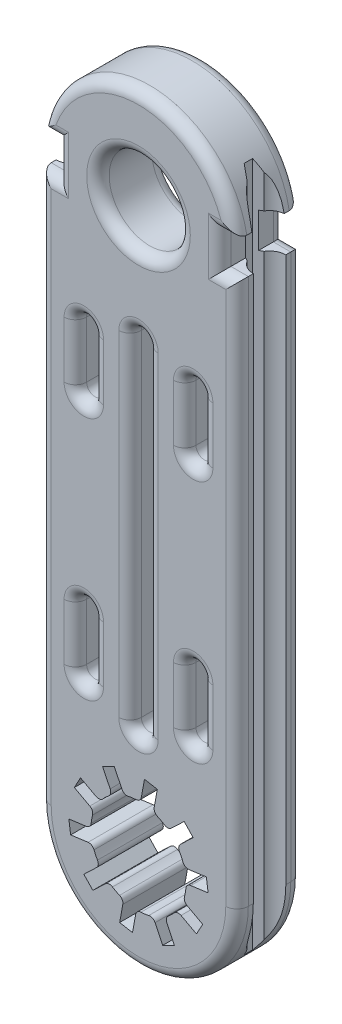
from build123d import *

# Parameters (mm, degrees)
SALIENTE_EXTRUIR1_DEPTH      = 3
SALIENTE_EXTRUIR1_DEPTH_BACK = 2.78
CROQUIS2_W                   = 17.498184
CROQUIS2_H                   = 5.77054
SALIENTE_EXTRUIR2_DEPTH      = 50
CROQUIS4_R                   = 8.749092
SALIENTE_EXTRUIR3_DEPTH      = 5.78
CROQUIS5_R                   = 3.6
CROQUIS5_R_2                 = 3.15
CORTAR_EXTRUIR1_DEPTH        = 12
CROQUIS6_W                   = 2.138247
CROQUIS6_H                   = 3.107333
CORTAR_EXTRUIR2_DEPTH        = 9
CORTAR_EXTRUIR3_DEPTH        = 10
CORTAR_EXTRUIR4_DEPTH        = 10
CROQUIS9_R                   = 63.746793
CORTAR_EXTRUIR5_DEPTH        = 3
REDONDEO1_R                  = 1
CORTAR_EXTRUIR6_DEPTH        = 73
CORTAR_EXTRUIR7_DEPTH        = 8


with BuildPart() as part:
    # Croquis1 → Saliente-Extruir1 (new body, two sides)
    with BuildSketch(Plane.XY) as saliente_extruir1_sk:
        with BuildLine():
            Line((-0.091551, 52.561209), (5.657541, 52.561209))
            ThreePointArc((5.657541, 52.561209), (8.657541, 49.561209), (11.657541, 52.561209))
            Line((11.657541, 52.561209), (17.406633, 52.561209))
            ThreePointArc((17.406633, 52.561209), (8.657541, 43.812117), (-0.091551, 52.561209))
        make_face()
    extrude(amount=SALIENTE_EXTRUIR1_DEPTH)
    extrude(saliente_extruir1_sk.sketch, amount=-SALIENTE_EXTRUIR1_DEPTH_BACK)

    # Croquis2 → Saliente-Extruir2 (add)
    with BuildSketch(Plane(origin=(0, 52.561209, 0), x_dir=(1, 0, 0), z_dir=(0, 1, 0))):
        with Locations((8.657541, -0.11473)):
            Rectangle(CROQUIS2_W, CROQUIS2_H)
    extrude(amount=SALIENTE_EXTRUIR2_DEPTH)

    # Croquis4 → Saliente-Extruir3 (add, through all)
    with BuildSketch(Plane.XY.offset(3)):
        with Locations((8.657541, 102.561209)):
            Circle(CROQUIS4_R)
    extrude(amount=-SALIENTE_EXTRUIR3_DEPTH)

    # Croquis5 → Cortar-Extruir1 (cut)
    with BuildSketch(Plane.XY.offset(3)):
        with Locations((8.657541, 102.561209)):
            Circle(CROQUIS5_R)
        with Locations((8.657541, 52.561209)):
            Circle(CROQUIS5_R_2)
    extrude(amount=-CORTAR_EXTRUIR1_DEPTH, mode=Mode.SUBTRACT)

    # Croquis6 → Cortar-Extruir2 (cut)
    with BuildSketch(Plane(origin=(0, 0, -2.78), x_dir=(-1, 0, 0), z_dir=(0, 0, -1))):
        with Locations((-0.387474, 102.534681)):
            Rectangle(CROQUIS6_W, CROQUIS6_H)
        with Locations((-16.927608, 102.534681)):
            Rectangle(CROQUIS6_W, CROQUIS6_H)
    extrude(amount=-CORTAR_EXTRUIR2_DEPTH, mode=Mode.SUBTRACT)

    # Croquis7 → Cortar-Extruir3 (cut)
    with BuildSketch(Plane.XY.offset(3)):
        with BuildLine():
            Line((12.761115, 63.99133), (12.761115, 68.99133))
            ThreePointArc((12.761115, 68.99133), (13.511115, 69.74133), (14.261115, 68.99133))
            Line((14.261115, 68.99133), (14.261115, 63.99133))
            ThreePointArc((14.261115, 63.99133), (13.511115, 63.24133), (12.761115, 63.99133))
        make_face()
        with BuildLine():
            Line((4.553967, 63.99133), (4.553967, 68.99133))
            ThreePointArc((4.553967, 68.99133), (3.803967, 69.74133), (3.053967, 68.99133))
            Line((3.053967, 68.99133), (3.053967, 63.99133))
            ThreePointArc((3.053967, 63.99133), (3.803967, 63.24133), (4.553967, 63.99133))
        make_face()
        with BuildLine():
            Line((12.761115, 90.684637), (12.761115, 85.684637))
            ThreePointArc((12.761115, 85.684637), (13.511115, 84.934637), (14.261115, 85.684637))
            Line((14.261115, 85.684637), (14.261115, 90.684637))
            ThreePointArc((14.261115, 90.684637), (13.511115, 91.434637), (12.761115, 90.684637))
        make_face()
        with BuildLine():
            Line((4.553967, 90.684637), (4.553967, 85.684637))
            ThreePointArc((4.553967, 85.684637), (3.803967, 84.934637), (3.053967, 85.684637))
            Line((3.053967, 85.684637), (3.053967, 90.684637))
            ThreePointArc((3.053967, 90.684637), (3.803967, 91.434637), (4.553967, 90.684637))
        make_face()
    extrude(amount=-CORTAR_EXTRUIR3_DEPTH, mode=Mode.SUBTRACT)

    # Croquis8 → Cortar-Extruir4 (cut)
    with BuildSketch(Plane(origin=(0, 0, -2.78), x_dir=(-1, 0, 0), z_dir=(0, 0, -1))):
        with BuildLine():
            Line((-7.907541, 92.084434), (-7.907541, 62.337983))
            ThreePointArc((-7.907541, 62.337983), (-8.657541, 61.587983), (-9.407541, 62.337983))
            Line((-9.407541, 62.337983), (-9.407541, 92.084434))
            ThreePointArc((-9.407541, 92.084434), (-8.657541, 92.834434), (-7.907541, 92.084434))
        make_face()
    extrude(amount=-CORTAR_EXTRUIR4_DEPTH, mode=Mode.SUBTRACT)

    # Croquis9 → Cortar-Extruir5 (cut)
    with BuildSketch(Plane(origin=(0, 0, -2.77054), x_dir=(-1, 0, 0), z_dir=(0, 0, -1))):
        with Locations((-8.657541, 52.561209)):
            Circle(CROQUIS9_R)
    extrude(amount=CORTAR_EXTRUIR5_DEPTH, mode=Mode.SUBTRACT)

    # Redondeo1
    redondeo1_edges = [part.edges().sort_by_distance(p)[0] for p in [
        (14.261115, 66.49133, -2.77054),
        (13.511115, 69.74133, -2.77054),
        (12.761115, 66.49133, -2.77054),
        (13.511115, 63.24133, -2.77054),
        (3.053967, 88.184637, -2.77054),
        (3.803967, 84.934637, -2.77054),
        (4.553967, 88.184637, -2.77054),
        (3.803967, 91.434637, -2.77054),
        (12.761115, 88.184637, -2.77054),
        (13.511115, 84.934637, -2.77054),
        (14.261115, 88.184637, -2.77054),
        (13.511115, 91.434637, -2.77054),
        (4.553967, 66.49133, -2.77054),
        (3.803967, 69.74133, -2.77054),
        (3.053967, 66.49133, -2.77054),
        (3.803967, 63.24133, -2.77054),
        (8.657541, 43.812117, 3),
        (3.803967, 63.24133, 3),
        (4.553967, 66.49133, 3),
        (3.803967, 69.74133, 3),
        (3.053967, 66.49133, 3),
        (13.511115, 91.434637, 3),
        (12.761115, 88.184637, 3),
        (13.511115, 84.934637, 3),
        (14.261115, 88.184637, 3),
        (3.803967, 91.434637, 3),
        (3.053967, 88.184637, 3),
        (3.803967, 84.934637, 3),
        (4.553967, 88.184637, 3),
        (13.511115, 63.24133, 3),
        (14.261115, 66.49133, 3),
        (13.511115, 69.74133, 3),
        (12.761115, 66.49133, 3),
        (9.407541, 77.211209, -2.77054),
        (8.657541, 61.587983, -2.77054),
        (7.907541, 77.211209, -2.77054),
        (8.657541, 92.834434, -2.77054),
        (8.657541, 92.834434, 3),
        (7.907541, 77.211209, 3),
        (8.657541, 61.587983, 3),
        (9.407541, 77.211209, 3),
        (8.657541, 111.310301, -2.77054),
        (8.657541, 43.812117, -2.77054),
        (1.456598, 102.53468, -2.77054),
        (0.749679, 104.088347, -2.77054),
        (16.565403, 104.088347, -2.77054),
        (15.858484, 102.53468, -2.77054),
        (5.057541, 102.561209, -2.77054),
        (5.507541, 52.561209, -2.77054),
        (5.507541, 52.561209, 3),
        (5.057541, 102.561209, 3),
        (8.657541, 111.310301, 3),
        (-0.091551, 76.771111, -2.77054),
        (17.406633, 76.771111, -2.77054),
        (17.406633, 76.771111, 3),
        (-0.091551, 76.771111, 3),
        (1.456598, 102.53468, 3),
        (0.749679, 104.088347, 3),
        (0.682523, 100.981014, 3),
        (0.682523, 100.981014, -2.77054),
        (15.858484, 102.53468, 3),
        (16.632558, 100.981014, 3),
        (16.565403, 104.088347, 3),
        (16.632558, 100.981014, -2.77054),
    ]]
    fillet(redondeo1_edges, radius=REDONDEO1_R)

    # Croquis10 → Cortar-Extruir6 (cut)
    with BuildSketch(Plane(origin=(0, 111.310301, 0), x_dir=(1, 0, 0), z_dir=(0, 1, 0))):
        with BuildLine():
            Line((15.52476, 0.26027), (16.174279, 0.63527))
            ThreePointArc((16.174279, 0.63527), (18.849268, -0.11473), (16.174279, -0.86473))
            Line((16.174279, -0.86473), (15.52476, -0.48973))
            Line((15.52476, -0.48973), (15.52476, 0.26027))
        make_face()
        with BuildLine():
            Line((1.140802, -0.86473), (1.790322, -0.48973))
            Line((1.790322, -0.48973), (1.790322, 0.26027))
            Line((1.790322, 0.26027), (1.140802, 0.63527))
            ThreePointArc((1.140802, 0.63527), (-1.534186, -0.11473), (1.140802, -0.86473))
        make_face()
    extrude(amount=-CORTAR_EXTRUIR6_DEPTH, mode=Mode.SUBTRACT)

    # Croquis14 → Cortar-Extruir7 (cut)
    with BuildSketch(Plane(origin=(0, 0, -2.77054), x_dir=(-1, 0, 0), z_dir=(0, 0, -1))):
        with BuildLine():
            Line((-10.050207, 56.982538), (-10.329063, 58.516443))
            Line((-10.329063, 58.516443), (-9.188954, 58.723709))
            Line((-9.188954, 58.723709), (-8.910099, 57.189804))
            ThreePointArc((-8.910099, 57.189804), (-8.748166, 56.903606), (-8.443498, 56.779877))
            ThreePointArc((-8.443498, 56.779877), (-8.091828, 56.747251), (-7.744112, 56.68536))
            ThreePointArc((-7.744112, 56.68536), (-7.417531, 56.72378), (-7.185439, 56.956728))
            Line((-7.185439, 56.956728), (-6.509431, 58.361591))
            Line((-6.509431, 58.361591), (-5.465236, 57.859132))
            Line((-5.465236, 57.859132), (-6.141244, 56.45427))
            ThreePointArc((-6.141244, 56.45427), (-6.178461, 56.12755), (-6.004705, 55.848372))
            ThreePointArc((-6.004705, 55.848372), (-5.739375, 55.61527), (-5.494446, 55.360818))
            ThreePointArc((-5.494446, 55.360818), (-5.207654, 55.19994), (-4.882964, 55.251979))
            Line((-4.882964, 55.251979), (-3.510305, 55.991189))
            Line((-3.510305, 55.991189), (-2.960871, 54.97093))
            Line((-2.960871, 54.97093), (-4.33353, 54.23172))
            ThreePointArc((-4.33353, 54.23172), (-4.55568, 53.989273), (-4.579206, 53.661282))
            ThreePointArc((-4.579206, 53.661282), (-4.501563, 53.316742), (-4.452974, 52.96692))
            ThreePointArc((-4.452974, 52.96692), (-4.315516, 52.668195), (-4.022249, 52.519447))
            Line((-4.022249, 52.519447), (-2.477247, 52.310652))
            Line((-2.477247, 52.310652), (-2.63244, 51.162295))
            Line((-2.63244, 51.162295), (-4.177441, 51.371091))
            ThreePointArc((-4.177441, 51.371091), (-4.499671, 51.305524), (-4.711492, 51.054001))
            ThreePointArc((-4.711492, 51.054001), (-4.851193, 50.729625), (-5.017504, 50.418054))
            ThreePointArc((-5.017504, 50.418054), (-5.081884, 50.095584), (-4.932057, 49.802867))
            Line((-4.932057, 49.802867), (-3.804852, 48.725819))
            Line((-3.804852, 48.725819), (-4.605392, 47.887998))
            Line((-4.605392, 47.887998), (-5.732597, 48.965046))
            ThreePointArc((-5.732597, 48.965046), (-6.031827, 49.101404), (-6.351034, 49.022423))
            ThreePointArc((-6.351034, 49.022423), (-6.654719, 48.842112), (-6.972404, 48.6878))
            ThreePointArc((-6.972404, 48.6878), (-7.214032, 48.464758), (-7.264874, 48.139879))
            Line((-7.264874, 48.139879), (-6.986019, 46.605974))
            Line((-6.986019, 46.605974), (-8.126128, 46.398709))
            Line((-8.126128, 46.398709), (-8.404983, 47.932614))
            ThreePointArc((-8.404983, 47.932614), (-8.566916, 48.218812), (-8.871584, 48.34254))
            ThreePointArc((-8.871584, 48.34254), (-9.223254, 48.375167), (-9.570969, 48.437057))
            ThreePointArc((-9.570969, 48.437057), (-9.897551, 48.398637), (-10.129642, 48.165689))
            Line((-10.129642, 48.165689), (-10.80565, 46.760827))
            Line((-10.80565, 46.760827), (-11.849845, 47.263285))
            Line((-11.849845, 47.263285), (-11.173837, 48.668147))
            ThreePointArc((-11.173837, 48.668147), (-11.136621, 48.994868), (-11.310377, 49.274046))
            ThreePointArc((-11.310377, 49.274046), (-11.575706, 49.507147), (-11.820635, 49.7616))
            ThreePointArc((-11.820635, 49.7616), (-12.107428, 49.922477), (-12.432118, 49.870438))
            Line((-12.432118, 49.870438), (-13.804777, 49.131228))
            Line((-13.804777, 49.131228), (-14.354211, 50.151488))
            Line((-14.354211, 50.151488), (-12.981552, 50.890697))
            ThreePointArc((-12.981552, 50.890697), (-12.759401, 51.133145), (-12.735876, 51.461136))
            ThreePointArc((-12.735876, 51.461136), (-12.813518, 51.805676), (-12.862107, 52.155498))
            ThreePointArc((-12.862107, 52.155498), (-12.999566, 52.454223), (-13.292833, 52.60297))
            Line((-13.292833, 52.60297), (-14.837834, 52.811766))
            Line((-14.837834, 52.811766), (-14.682642, 53.960122))
            Line((-14.682642, 53.960122), (-13.137641, 53.751326))
            ThreePointArc((-13.137641, 53.751326), (-12.815411, 53.816894), (-12.60359, 54.068416))
            ThreePointArc((-12.60359, 54.068416), (-12.463888, 54.392792), (-12.297577, 54.704364))
            ThreePointArc((-12.297577, 54.704364), (-12.233198, 55.026833), (-12.383024, 55.319551))
            Line((-12.383024, 55.319551), (-13.510229, 56.396599))
            Line((-13.510229, 56.396599), (-12.709689, 57.234419))
            Line((-12.709689, 57.234419), (-11.582484, 56.157371))
            ThreePointArc((-11.582484, 56.157371), (-11.283255, 56.021014), (-10.964047, 56.099995))
            ThreePointArc((-10.964047, 56.099995), (-10.660363, 56.280306), (-10.342677, 56.434617))
            ThreePointArc((-10.342677, 56.434617), (-10.10105, 56.657659), (-10.050207, 56.982538))
        make_face()
    extrude(amount=-CORTAR_EXTRUIR7_DEPTH, mode=Mode.SUBTRACT)


solid = part.part
